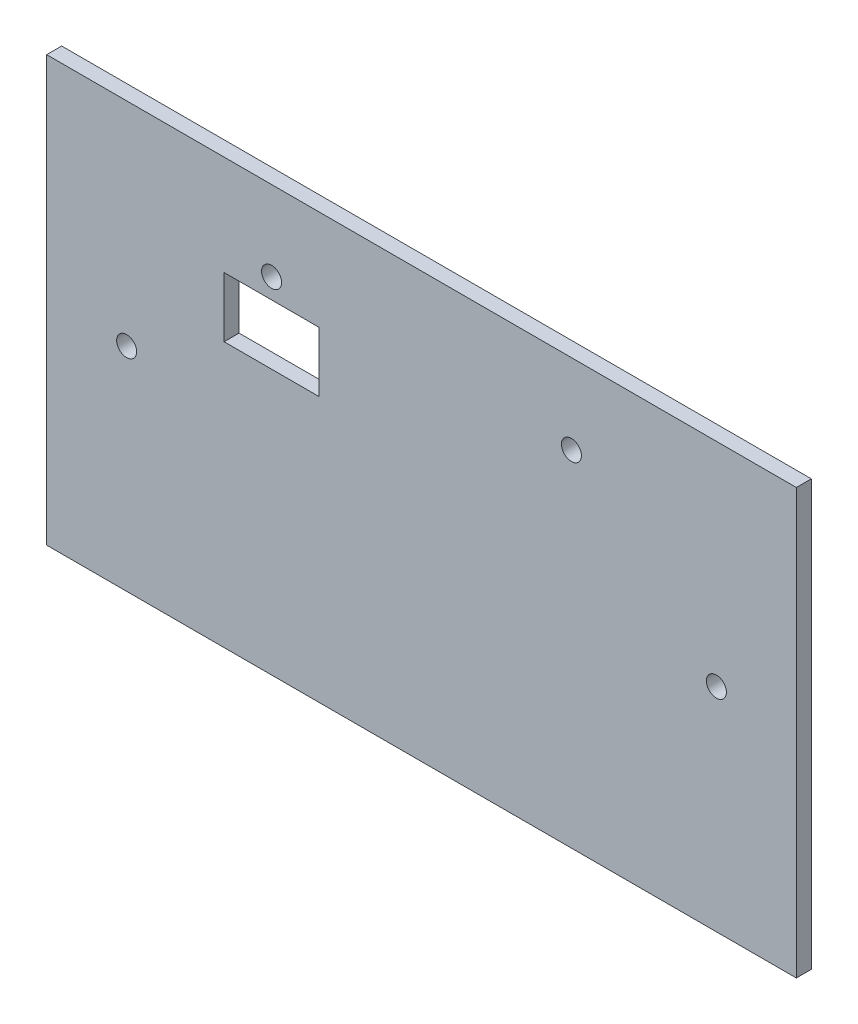
from build123d import *

# Parameters (mm, degrees)
SKETCH1_W           = 150
SKETCH1_H           = 85
BOSS_EXTRUDE1_DEPTH = 3
SKETCH2_R           = 2
CUT_EXTRUDE1_DEPTH  = 3
SKETCH3_R           = 2
CUT_EXTRUDE2_DEPTH  = 3
CUT_EXTRUDE4_REACH  = 5
SKETCH5_W           = 19
SKETCH5_H           = 12


with BuildPart() as part:
    # Sketch1 → Boss-Extrude1 (new body)
    with BuildSketch(Plane.XY):
        Rectangle(SKETCH1_W, SKETCH1_H)
    extrude(amount=BOSS_EXTRUDE1_DEPTH)

    # Sketch2 → Cut-Extrude1 (cut)
    with BuildSketch(Plane.XY.offset(3)):
        with Locations((-30, 26.5)):
            Circle(SKETCH2_R)
    cut_extrude1 = extrude(amount=-CUT_EXTRUDE1_DEPTH, mode=Mode.SUBTRACT)

    # Mirror1: Cut-Extrude1 across plane
    add(cut_extrude1.mirror(Plane(origin=(0, 0, 0), x_dir=(0, 0, 1), z_dir=(1, 0, 0))), mode=Mode.SUBTRACT)

    # Sketch3 → Cut-Extrude2 (cut)
    with BuildSketch(Plane.XY.offset(3)):
        with Locations((-59, 0)):
            Circle(SKETCH3_R)
    cut_extrude2 = extrude(amount=-CUT_EXTRUDE2_DEPTH, mode=Mode.SUBTRACT)

    # Mirror2: Cut-Extrude2 across plane
    add(cut_extrude2.mirror(Plane(origin=(0, 0, 0), x_dir=(0, 0, 1), z_dir=(1, 0, 0))), mode=Mode.SUBTRACT)

    # Sketch5 → Cut-Extrude4 (cut, up to next)
    with BuildSketch(Plane.XY.offset(3), mode=Mode.PRIVATE) as cut_extrude4_sk1:
        with Locations((-30, 16.5)):
            Rectangle(SKETCH5_W, SKETCH5_H)
    cut_extrude4_tool1 = extrude(cut_extrude4_sk1.sketch, amount=-CUT_EXTRUDE4_REACH, mode=Mode.PRIVATE) & part.part
    add(cut_extrude4_tool1.solids().sort_by_distance((-30, 16.5, 3))[0], mode=Mode.SUBTRACT)


solid = part.part
